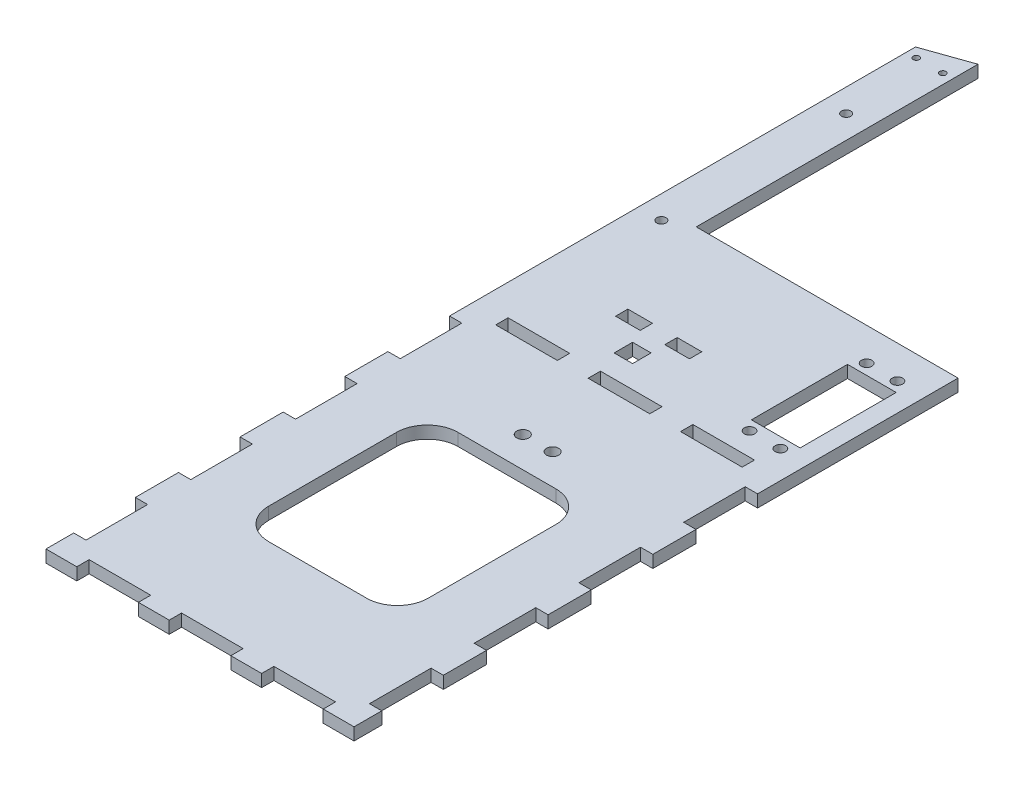
from build123d import *

# Parameters (mm, degrees)
BOSS_EXTRUDE1_DEPTH = 5.08
SKETCH3_W           = 20.066
SKETCH3_H           = 39.624
CUT_EXTRUDE1_DEPTH  = 5.08
SKETCH4_R           = 2.159
CUT_EXTRUDE2_DEPTH  = 5.08
CUT_EXTRUDE3_DEPTH  = 5.08
SKETCH6_W           = 5.08
SKETCH6_H           = 25.4
CUT_EXTRUDE4_DEPTH  = 5.08
SKETCH7_W           = 5.08
SKETCH7_H           = 25.4
CUT_EXTRUDE5_DEPTH  = 5.08
SKETCH8_W           = 5.08
SKETCH8_H           = 25.4
CUT_EXTRUDE6_DEPTH  = 5.08
SKETCH9_W           = 5.08
SKETCH9_H           = 25.4
CUT_EXTRUDE7_DEPTH  = 5.08
SKETCH10_W          = 25.4
SKETCH10_H          = 5.08
CUT_EXTRUDE8_DEPTH  = 5.08
SKETCH11_W          = 25.4
SKETCH11_H          = 5.08
CUT_EXTRUDE9_DEPTH  = 5.08
SKETCH12_R          = 1.27
CUT_EXTRUDE10_DEPTH = 5.08
SKETCH13_W          = 10.16
SKETCH13_H          = 5.08
CUT_EXTRUDE11_DEPTH = 5.08
SKETCH14_W          = 7.62
SKETCH14_H          = 7.62
CUT_EXTRUDE12_DEPTH = 5.08
SKETCH15_R          = 1.905
CUT_EXTRUDE13_DEPTH = 5.08
SKETCH16_R          = 2.49555
CUT_EXTRUDE14_DEPTH = 5.08


with BuildPart() as part:
    # Sketch2 → Boss-Extrude1 (new body)
    with BuildSketch(Plane(origin=(0, 0, 0), x_dir=(1, 0, 0), z_dir=(0, 1, 0))):
        Polygon((-19.05, -71.23934806), (-19.05, -249.03934806), (107.95, -249.03934806), (107.95, -60.96), (107.95, 0), (0, 0), (0, 65.786), (0, 97.473109619), (0, 116.165799875), (-19.05, 109.450065503), align=None)
    extrude(amount=BOSS_EXTRUDE1_DEPTH)

    # Sketch3 → Cut-Extrude1 (cut)
    with BuildSketch(Plane(origin=(0, 5.08, 0), x_dir=(1, 0, 0), z_dir=(0, 1, 0))):
        with Locations((90.297, -37.703734372)):
            Rectangle(SKETCH3_W, SKETCH3_H)
    extrude(amount=-CUT_EXTRUDE1_DEPTH, mode=Mode.SUBTRACT)

    # Sketch4 → Cut-Extrude2 (cut)
    with BuildSketch(Plane(origin=(0, 5.08, 0), x_dir=(1, 0, 0), z_dir=(0, 1, 0))):
        with Locations((83.82, -13.573734372)):
            Circle(SKETCH4_R)
        with Locations((96.52, -13.573734372)):
            Circle(SKETCH4_R)
        with Locations((83.82, -61.833734372)):
            Circle(SKETCH4_R)
        with Locations((96.52, -61.833734372)):
            Circle(SKETCH4_R)
    extrude(amount=-CUT_EXTRUDE2_DEPTH, mode=Mode.SUBTRACT)

    # Sketch5 → Cut-Extrude3 (cut)
    with BuildSketch(Plane(origin=(0, 5.08, 0), x_dir=(1, 0, 0), z_dir=(0, 1, 0))):
        with BuildLine():
            Line((24.257, -122.461402467), (64.611105155, -122.461402467))
            ThreePointArc((64.611105155, -122.461402467), (73.591361276, -126.181146346), (77.311105155, -135.161402467))
            Line((77.311105155, -135.161402467), (77.311105155, -187.819065756))
            ThreePointArc((77.311105155, -187.819065756), (73.591361276, -196.799321877), (64.611105155, -200.519065756))
            Line((64.611105155, -200.519065756), (24.257, -200.519065756))
            ThreePointArc((24.257, -200.519065756), (15.276743879, -196.799321877), (11.557, -187.819065756))
            Line((11.557, -187.819065756), (11.557, -135.161402467))
            ThreePointArc((11.557, -135.161402467), (15.276743879, -126.181146346), (24.257, -122.461402467))
        make_face()
    extrude(amount=-CUT_EXTRUDE3_DEPTH, mode=Mode.SUBTRACT)

    # Sketch6 → Cut-Extrude4 (cut)
    with BuildSketch(Plane(origin=(0, 5.08, 0), x_dir=(1, 0, 0), z_dir=(0, 1, 0))):
        with Locations((105.41, -224.90934806)):
            Rectangle(SKETCH6_W, SKETCH6_H)
    extrude(amount=-CUT_EXTRUDE4_DEPTH, mode=Mode.SUBTRACT)

    # Sketch7 → Cut-Extrude5 (cut)
    with BuildSketch(Plane(origin=(0, 5.08, 0), x_dir=(1, 0, 0), z_dir=(0, 1, 0))):
        with Locations((105.41, -181.72934806)):
            Rectangle(SKETCH7_W, SKETCH7_H)
    extrude(amount=-CUT_EXTRUDE5_DEPTH, mode=Mode.SUBTRACT)

    # Sketch8 → Cut-Extrude6 (cut)
    with BuildSketch(Plane(origin=(0, 5.08, 0), x_dir=(1, 0, 0), z_dir=(0, 1, 0))):
        with Locations((105.41, -138.54934806)):
            Rectangle(SKETCH8_W, SKETCH8_H)
        with Locations((105.41, -95.36934806)):
            Rectangle(SKETCH8_W, SKETCH8_H)
    extrude(amount=-CUT_EXTRUDE6_DEPTH, mode=Mode.SUBTRACT)

    # Sketch9 → Cut-Extrude7 (cut)
    with BuildSketch(Plane(origin=(0, 5.08, 0), x_dir=(1, 0, 0), z_dir=(0, 1, 0))):
        with Locations((-16.51, -224.90934806)):
            Rectangle(SKETCH9_W, SKETCH9_H)
        with Locations((-16.51, -181.72934806)):
            Rectangle(SKETCH9_W, SKETCH9_H)
        with Locations((-16.51, -138.54934806)):
            Rectangle(SKETCH9_W, SKETCH9_H)
        with Locations((-16.51, -95.36934806)):
            Rectangle(SKETCH9_W, SKETCH9_H)
    extrude(amount=-CUT_EXTRUDE7_DEPTH, mode=Mode.SUBTRACT)

    # Sketch10 → Cut-Extrude8 (cut)
    with BuildSketch(Plane(origin=(0, 5.08, 0), x_dir=(1, 0, 0), z_dir=(0, 1, 0))):
        with Locations((6.35, -73.77934806)):
            Rectangle(SKETCH10_W, SKETCH10_H)
        with Locations((44.45, -73.77934806)):
            Rectangle(SKETCH10_W, SKETCH10_H)
        with Locations((82.55, -73.77934806)):
            Rectangle(SKETCH10_W, SKETCH10_H)
    extrude(amount=-CUT_EXTRUDE8_DEPTH, mode=Mode.SUBTRACT)

    # Sketch11 → Cut-Extrude9 (cut)
    with BuildSketch(Plane(origin=(0, 5.08, 0), x_dir=(1, 0, 0), z_dir=(0, 1, 0))):
        with Locations((6.35, -246.49934806)):
            Rectangle(SKETCH11_W, SKETCH11_H)
        with Locations((44.45, -246.49934806)):
            Rectangle(SKETCH11_W, SKETCH11_H)
        with Locations((82.55, -246.49934806)):
            Rectangle(SKETCH11_W, SKETCH11_H)
    extrude(amount=-CUT_EXTRUDE9_DEPTH, mode=Mode.SUBTRACT)

    # Sketch12 → Cut-Extrude10 (cut)
    with BuildSketch(Plane(origin=(0, 5.08, 0), x_dir=(1, 0, 0), z_dir=(0, 1, 0))):
        with Locations((-14.998025324, 105.700929136)):
            Circle(SKETCH12_R)
        with Locations((-4.064, 105.700929136)):
            Circle(SKETCH12_R)
    extrude(amount=-CUT_EXTRUDE10_DEPTH, mode=Mode.SUBTRACT)

    # Sketch13 → Cut-Extrude11 (cut)
    with BuildSketch(Plane(origin=(0, 5.08, 0), x_dir=(1, 0, 0), z_dir=(0, 1, 0))):
        with Locations((20.32, -45.974710139)):
            Rectangle(SKETCH13_W, SKETCH13_H)
        with Locations((40.64, -45.974710139)):
            Rectangle(SKETCH13_W, SKETCH13_H)
    extrude(amount=-CUT_EXTRUDE11_DEPTH, mode=Mode.SUBTRACT)

    # Sketch14 → Cut-Extrude12 (cut)
    with BuildSketch(Plane(origin=(0, 5.08, 0), x_dir=(1, 0, 0), z_dir=(0, 1, 0))):
        with Locations((31.877, -58.119790423)):
            Rectangle(SKETCH14_W, SKETCH14_H)
    extrude(amount=-CUT_EXTRUDE12_DEPTH, mode=Mode.SUBTRACT)

    # Sketch15 → Cut-Extrude13 (cut)
    with BuildSketch(Plane(origin=(0, 5.08, 0), x_dir=(1, 0, 0), z_dir=(0, 1, 0))):
        with Locations((-9.5377, 71.350065503)):
            Circle(SKETCH15_R)
        with Locations((-9.5377, -4.849934497)):
            Circle(SKETCH15_R)
    extrude(amount=-CUT_EXTRUDE13_DEPTH, mode=Mode.SUBTRACT)

    # Sketch16 → Cut-Extrude14 (cut)
    with BuildSketch(Plane(origin=(0, 5.08, 0), x_dir=(1, 0, 0), z_dir=(0, 1, 0))):
        with Locations((38.354, -109.869872905)):
            Circle(SKETCH16_R)
        with Locations((50.658638695, -109.869872905)):
            Circle(SKETCH16_R)
    extrude(amount=-CUT_EXTRUDE14_DEPTH, mode=Mode.SUBTRACT)


solid = part.part
